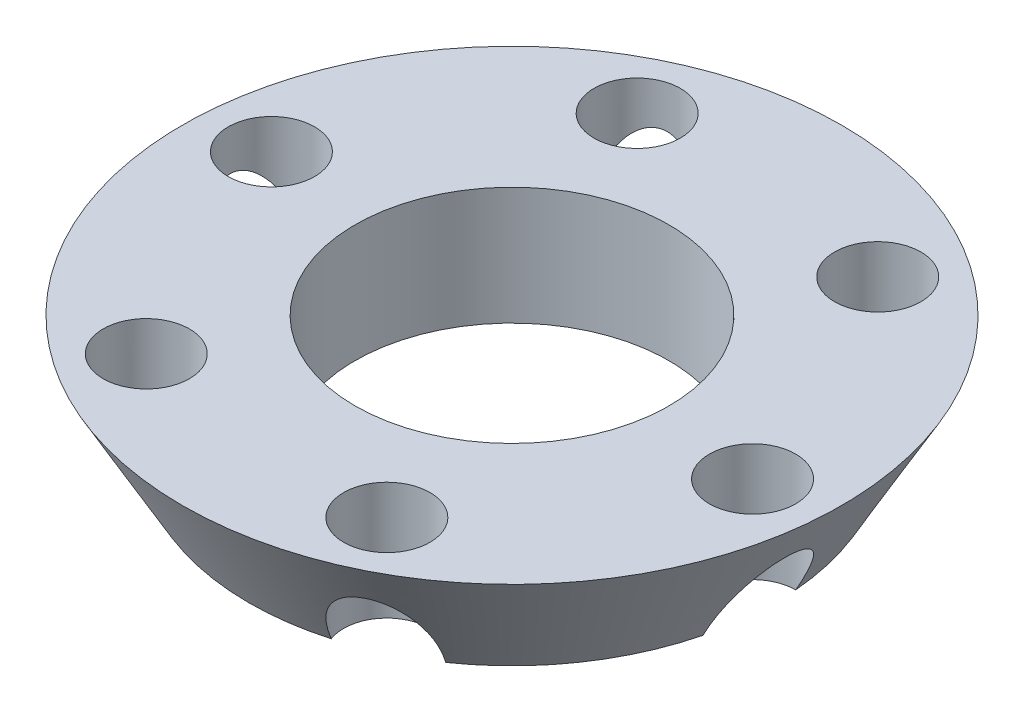
from build123d import *

# Parameters (mm, degrees)
SKETCH1_R          = 16.75
SKETCH2_R          = 21
SKETCH1_4_R        = 2.75
SKETCH1_4_R_2      = 10
CUT_EXTRUDE1_DEPTH = 31.630866947


with BuildPart() as part:
    # Sketch1 → Loft1 section 0
    with BuildSketch(Plane(origin=(0, 0, 0), x_dir=(1, 0, 0), z_dir=(0, 1, 0))):
        Circle(SKETCH1_R)
    # Sketch2 → Loft1 section 1
    with BuildSketch(Plane(origin=(0, 7.5, 0), x_dir=(1, 0, 0), z_dir=(0, 1, 0))):
        Circle(SKETCH2_R)
    loft()

    # Sketch1_4 → Cut-Extrude1 (cut, through all)
    with BuildSketch(Plane(origin=(0, 0, 0), x_dir=(1, 0, 0), z_dir=(0, 1, 0))):
        with Locations((16.694272111, -1.365202803)):
            Circle(SKETCH1_4_R)
        with Locations((9.529436364, 13.775062344)):
            Circle(SKETCH1_4_R)
        with Locations((7.164835747, -15.140265147)):
            Circle(SKETCH1_4_R)
        with Locations((-7.164835747, 15.140265147)):
            Circle(SKETCH1_4_R)
        with Locations((-9.529436364, -13.775062344)):
            Circle(SKETCH1_4_R)
        with Locations((-16.694272111, 1.365202803)):
            Circle(SKETCH1_4_R)
        Circle(SKETCH1_4_R_2)
    extrude(amount=CUT_EXTRUDE1_DEPTH, mode=Mode.SUBTRACT)


solid = part.part
